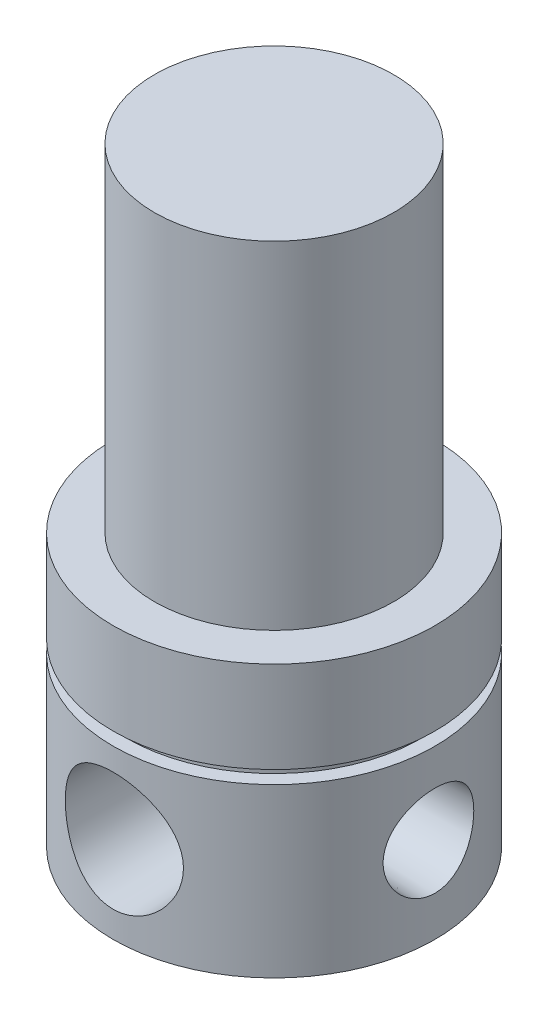
from build123d import *


with BuildPart() as part:
    # Sketch1 → Revolve1 (revolve)
    with BuildSketch(Plane(origin=(0, 0, 0), x_dir=(0, 0, -1), z_dir=(1, 0, 0))):
        Polygon((0, 50.038), (13.97, 50.038), (13.97, 10.668), (18.796, 10.668), (18.796, 0), (17.2085, 0), (17.2085, -1.524), (18.796, -1.524), (18.796, -21.082), (0, -21.082), align=None)
    revolve(axis=Axis((0, 33.650567532, 0), (0, -1, 0)))


with BuildPart() as body_2:
    # Split1: the piece on the far side of the plane
    add(part.part)
    split(bisect_by=Plane(origin=(0, 0, 0), x_dir=(0, 0, -1), z_dir=(0, -1, 0)), keep=Keep.BOTTOM)


with BuildPart() as part_1:
    add(part.part)

    # Split1
    split(bisect_by=Plane(origin=(0, 0, 0), x_dir=(0, 0, -1), z_dir=(0, -1, 0)), keep=Keep.TOP)

    # Sketch3 → 1_8 NPT Tapped Hole1 (revolve, cut)
    with BuildSketch(Plane(origin=(18.796, -11.082, 0), x_dir=(0, 0, -1), z_dir=(0, 1, 0))):
        Polygon((0, 0), (0, 16.503468714), (4.2164, 13.97), (4.2164, 12.7), (4.936180893, 12.7), (5.3164359, 0), align=None)
    f_1_8_npt_tapped_hole1 = revolve(axis=Axis((25.146, -11.082, 0), (-1, 0, 0)), mode=Mode.SUBTRACT)

    # Mirror1: 1_8 NPT Tapped Hole1 across plane
    add(f_1_8_npt_tapped_hole1.mirror(Plane(origin=(0, 0, 0), x_dir=(0, 0, 1), z_dir=(1, 0, 0))), mode=Mode.SUBTRACT)

    # Sketch5 → 1_4 NPT Tapped Hole1 (revolve, cut)
    with BuildSketch(Plane(origin=(0, -11.082, -18.796), x_dir=(0, 1, 0), z_dir=(1, 0, 0))):
        Polygon((0, 0), (0, 17.312347279), (5.5626, 13.97), (5.5626, 12.7), (6.557983593, 12.7), (6.9382386, 0), align=None)
    f_1_4_npt_tapped_hole1 = revolve(axis=Axis((0, -11.082, -25.146), (0, 0, 1)), mode=Mode.SUBTRACT)

    # Mirror2: 1_4 NPT Tapped Hole1 across plane
    add(f_1_4_npt_tapped_hole1.mirror(Plane.XY), mode=Mode.SUBTRACT)


solid = Compound([body_2.part, part_1.part])
